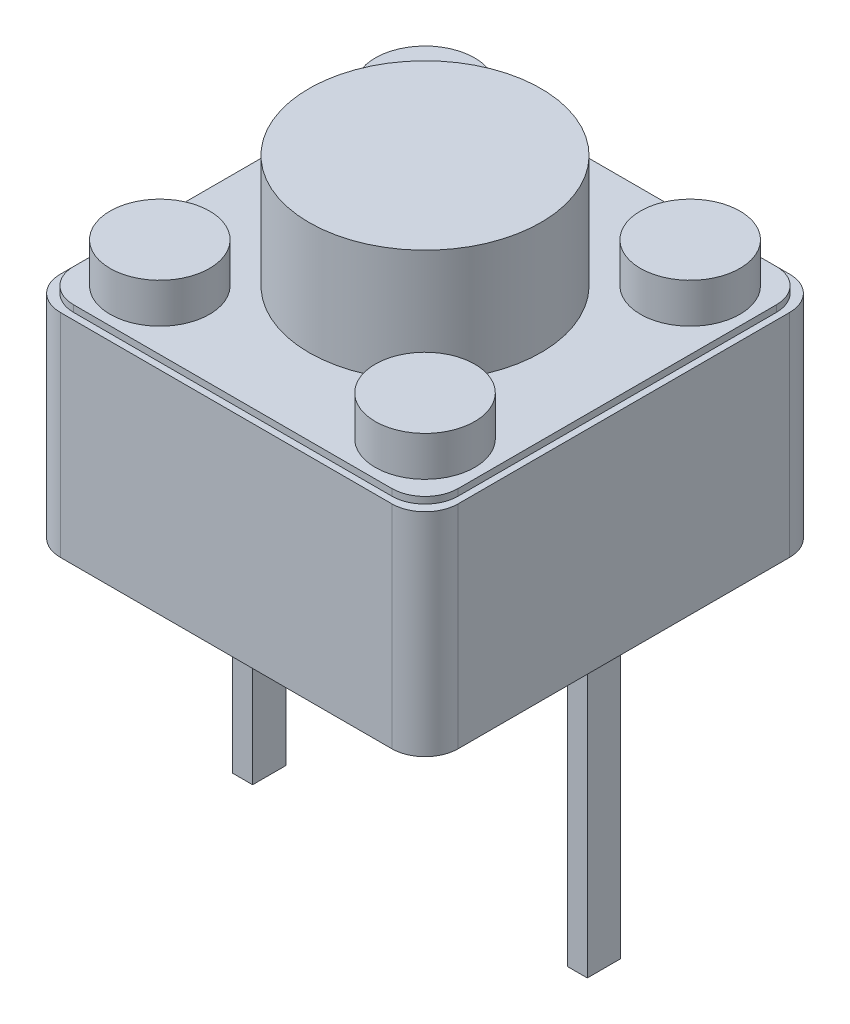
from build123d import *

# Parameters (mm, degrees)
ESBO_O1_W                = 6
ESBO_O1_H                = 6
RESSALTO_EXTRUS_O1_DEPTH = 3.4
ESBO_O2_R                = 1.75
RESSALTO_EXTRUS_O2_DEPTH = 1.6
ESBO_O3_R                = 0.75
RESSALTO_EXTRUS_O3_DEPTH = 0.5
ESBO_O5_W                = 0.3
ESBO_O5_H                = 0.5
RESSALTO_EXTRUS_O4_DEPTH = 4.27
ESBO_O6_W                = 6
ESBO_O6_H                = 6
CORTE_EXTRUS_O1_DEPTH    = 0.6
ESBO_O7_W                = 6
ESBO_O7_H                = 6
RESSALTO_EXTRUS_O5_DEPTH = 0.6
ESBO_O9_W                = 6
ESBO_O9_H                = 6
CORTE_EXTRUS_O2_DEPTH    = 0.2
ESBO_O10_W               = 5.8
ESBO_O10_H               = 5.8
RESSALTO_EXTRUS_O6_DEPTH = 0.1
FILETE3_R                = 0.5
FILETE4_R                = 0.5
ESBO_O12_R               = 1.75
ESBO_O12_R_2             = 0.759056116
ESBO_O12_R_3             = 0.75
RESSALTO_EXTRUS_O7_DEPTH = 0.5


with BuildPart() as part:
    # Esboço1 → Ressalto-extrusão1 (new body)
    with BuildSketch(Plane(origin=(0, 0, 0), x_dir=(1, 0, 0), z_dir=(0, 1, 0))):
        with Locations((-7, 7.272727273)):
            Rectangle(ESBO_O1_W, ESBO_O1_H)
    extrude(amount=RESSALTO_EXTRUS_O1_DEPTH)

    # Esboço2 → Ressalto-extrusão2 (add)
    with BuildSketch(Plane(origin=(0, 3.4, 0), x_dir=(1, 0, 0), z_dir=(0, 1, 0))):
        with Locations((-7, 7.272727273)):
            Circle(ESBO_O2_R)
    extrude(amount=RESSALTO_EXTRUS_O2_DEPTH)

    # Esboço3 → Ressalto-extrusão3 (add)
    with BuildSketch(Plane(origin=(0, 3.4, 0), x_dir=(1, 0, 0), z_dir=(0, 1, 0))):
        with Locations((-9, 9.272727273)):
            Circle(ESBO_O3_R)
        with Locations((-5, 9.272727273)):
            Circle(ESBO_O3_R)
        with Locations((-9, 5.272727273)):
            Circle(ESBO_O3_R)
        with Locations((-5, 5.272727273)):
            Circle(ESBO_O3_R)
    extrude(amount=RESSALTO_EXTRUS_O3_DEPTH)

    # Esboço5 → Ressalto-extrusão4 (add)
    with BuildSketch(Plane.XZ):
        with Locations((-9.5, -7.272727273)):
            Rectangle(ESBO_O5_W, ESBO_O5_H)
        with Locations((-4.452085856, -7.272727273)):
            Rectangle(ESBO_O5_W, ESBO_O5_H)
    extrude(amount=RESSALTO_EXTRUS_O4_DEPTH)

    # Esboço6 → Corte-extrusão1 (cut)
    with BuildSketch(Plane(origin=(0, 3.4, 0), x_dir=(1, 0, 0), z_dir=(0, 1, 0))):
        with Locations((-7, 7.272727273)):
            Rectangle(ESBO_O6_W, ESBO_O6_H)
    extrude(amount=-CORTE_EXTRUS_O1_DEPTH, mode=Mode.SUBTRACT)

    # Esboço7 → Ressalto-extrusão5 (add)
    with BuildSketch(Plane(origin=(0, 2.8, 0), x_dir=(1, 0, 0), z_dir=(0, 1, 0))):
        with Locations((-7, 7.272727273)):
            Rectangle(ESBO_O7_W, ESBO_O7_H)
    extrude(amount=RESSALTO_EXTRUS_O5_DEPTH)

    # Esboço9 → Corte-extrusão2 (cut)
    with BuildSketch(Plane(origin=(0, 3.4, 0), x_dir=(1, 0, 0), z_dir=(0, 1, 0))):
        with Locations((-7, 7.272727273)):
            Rectangle(ESBO_O9_W, ESBO_O9_H)
    extrude(amount=-CORTE_EXTRUS_O2_DEPTH, mode=Mode.SUBTRACT)

    # Esboço10 → Ressalto-extrusão6 (add)
    with BuildSketch(Plane(origin=(0, 3.2, 0), x_dir=(1, 0, 0), z_dir=(0, 1, 0))):
        with Locations((-7, 7.272727273)):
            Rectangle(ESBO_O10_W, ESBO_O10_H)
    extrude(amount=RESSALTO_EXTRUS_O6_DEPTH)

    # Filete3
    filete3_edges = [part.edges().sort_by_distance(p)[0] for p in [
        (-9.9, 3.25, -10.172727273),
        (-9.9, 3.25, -4.372727273),
        (-4.1, 3.25, -4.372727273),
        (-4.1, 3.25, -10.172727273),
    ]]
    fillet(filete3_edges, radius=FILETE3_R)

    # Filete4
    filete4_edges = [part.edges().sort_by_distance(p)[0] for p in [
        (-10, 1.6, -10.272727273),
        (-10, 1.6, -4.272727273),
        (-4, 1.6, -4.272727273),
        (-4, 1.6, -10.272727273),
    ]]
    fillet(filete4_edges, radius=FILETE4_R)

    # Esboço12 → Ressalto-extrusão7 (add)
    with BuildSketch(Plane(origin=(0, 3.3, 0), x_dir=(1, 0, 0), z_dir=(0, 1, 0))):
        with Locations((-7, 7.272727273)):
            Circle(ESBO_O12_R)
        with Locations((-9, 9.272727273)):
            Circle(ESBO_O12_R_2)
        with Locations((-5, 9.272727273)):
            Circle(ESBO_O12_R_3)
        with Locations((-5, 5.272727273)):
            Circle(ESBO_O12_R_3)
        with Locations((-9, 5.272727273)):
            Circle(ESBO_O12_R_3)
    extrude(amount=RESSALTO_EXTRUS_O7_DEPTH)


solid = part.part
